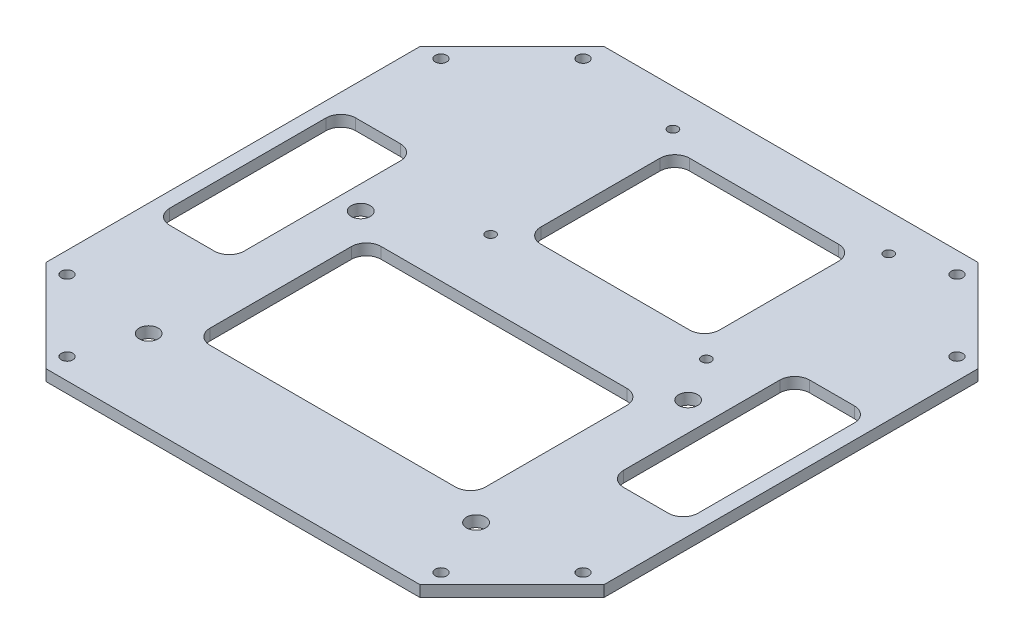
from build123d import *

# Parameters (mm, degrees)
SKETCH1_W           = 150
SKETCH1_H           = 150
BOSS_EXTRUDE1_DEPTH = 1.5
CUT_EXTRUDE1_DEPTH  = 3
SKETCH3_R           = 1.55
CUT_EXTRUDE2_DEPTH  = 3
SKETCH6_R           = 1.3
SKETCH6_R_2         = 2.55
CUT_EXTRUDE9_DEPTH  = 3
SKETCH7_W           = 20
SKETCH7_H           = 50
SKETCH7_W_2         = 48
SKETCH7_H_2         = 40
SKETCH7_W_3         = 74
SKETCH7_H_3         = 46
CUT_EXTRUDE10_DEPTH = 3
FILLET1_R           = 4


with BuildPart() as part:
    # Sketch1 → Boss-Extrude1 (new body, symmetric)
    with BuildSketch(Plane(origin=(0, 0, 0), x_dir=(1, 0, 0), z_dir=(0, 1, 0))):
        Rectangle(SKETCH1_W, SKETCH1_H)
    extrude(amount=BOSS_EXTRUDE1_DEPTH, both=True)

    # Sketch2 → Cut-Extrude1 (cut)
    with BuildSketch(Plane(origin=(0, 1.5, 0), x_dir=(1, 0, 0), z_dir=(0, 1, 0))):
        Polygon((50.251262658, 75), (75, 75), (75, 50.251262658), align=None)
        Polygon((-75, 75), (-75, 50.251262658), (-50.251262658, 75), align=None)
        Polygon((-50.251262658, -75), (-75, -75), (-75, -50.251262658), align=None)
        Polygon((75, -75), (75, -50.251262658), (50.251262658, -75), align=None)
    extrude(amount=-CUT_EXTRUDE1_DEPTH, mode=Mode.SUBTRACT)

    # Sketch3 → Cut-Extrude2 (cut)
    with BuildSketch(Plane(origin=(0, 1.5, 0), x_dir=(1, 0, 0), z_dir=(0, 1, 0))):
        with Locations((69.343145751, 50.251262658)):
            Circle(SKETCH3_R)
        with Locations((50.251262658, 69.343145751)):
            Circle(SKETCH3_R)
        with Locations((-69.343145751, 50.251262658)):
            Circle(SKETCH3_R)
        with Locations((-50.251262658, 69.343145751)):
            Circle(SKETCH3_R)
        with Locations((-69.343145751, -50.251262658)):
            Circle(SKETCH3_R)
        with Locations((-50.251262658, -69.343145751)):
            Circle(SKETCH3_R)
        with Locations((69.343145751, -50.251262658)):
            Circle(SKETCH3_R)
        with Locations((50.251262658, -69.343145751)):
            Circle(SKETCH3_R)
    extrude(amount=-CUT_EXTRUDE2_DEPTH, mode=Mode.SUBTRACT)

    # Sketch6 → Cut-Extrude9 (cut)
    with BuildSketch(Plane(origin=(0, 1.5, 0), x_dir=(1, 0, 0), z_dir=(0, 1, 0))):
        with Locations((36.251262658, 16)):
            Circle(SKETCH6_R)
        with Locations((-21.748737342, 16)):
            Circle(SKETCH6_R)
        with Locations((36.251262658, 65)):
            Circle(SKETCH6_R)
        with Locations((-21.748737342, 65)):
            Circle(SKETCH6_R)
        with Locations((-44.656854249, 4)):
            Circle(SKETCH6_R_2)
        with Locations((-44.656854249, -53)):
            Circle(SKETCH6_R_2)
        with Locations((43.343145751, 4)):
            Circle(SKETCH6_R_2)
        with Locations((43.343145751, -53)):
            Circle(SKETCH6_R_2)
    extrude(amount=-CUT_EXTRUDE9_DEPTH, mode=Mode.SUBTRACT)

    # Sketch7 → Cut-Extrude10 (cut)
    with BuildSketch(Plane(origin=(0, 1.5, 0), x_dir=(1, 0, 0), z_dir=(0, 1, 0))):
        with Locations((61, 0)):
            Rectangle(SKETCH7_W, SKETCH7_H)
        with Locations((-61, 0)):
            Rectangle(SKETCH7_W, SKETCH7_H)
        with Locations((7.251262658, 40.5)):
            Rectangle(SKETCH7_W_2, SKETCH7_H_2)
        with Locations((-0.656854249, -24.5)):
            Rectangle(SKETCH7_W_3, SKETCH7_H_3)
    extrude(amount=-CUT_EXTRUDE10_DEPTH, mode=Mode.SUBTRACT)

    # Fillet1
    fillet1_edges = [part.edges().sort_by_distance(p)[0] for p in [
        (51, 0, 25),
        (51, 0, -25),
        (71, 0, -25),
        (71, 0, 25),
        (36.343145751, 0, 1.5),
        (36.343145751, 0, 47.5),
        (-37.656854249, 0, 47.5),
        (-37.656854249, 0, 1.5),
        (31.251262658, 0, -60.5),
        (31.251262658, 0, -20.5),
        (-16.748737342, 0, -20.5),
        (-16.748737342, 0, -60.5),
        (-71, 0, 25),
        (-71, 0, -25),
        (-51, 0, -25),
        (-51, 0, 25),
    ]]
    fillet(fillet1_edges, radius=FILLET1_R)


solid = part.part
